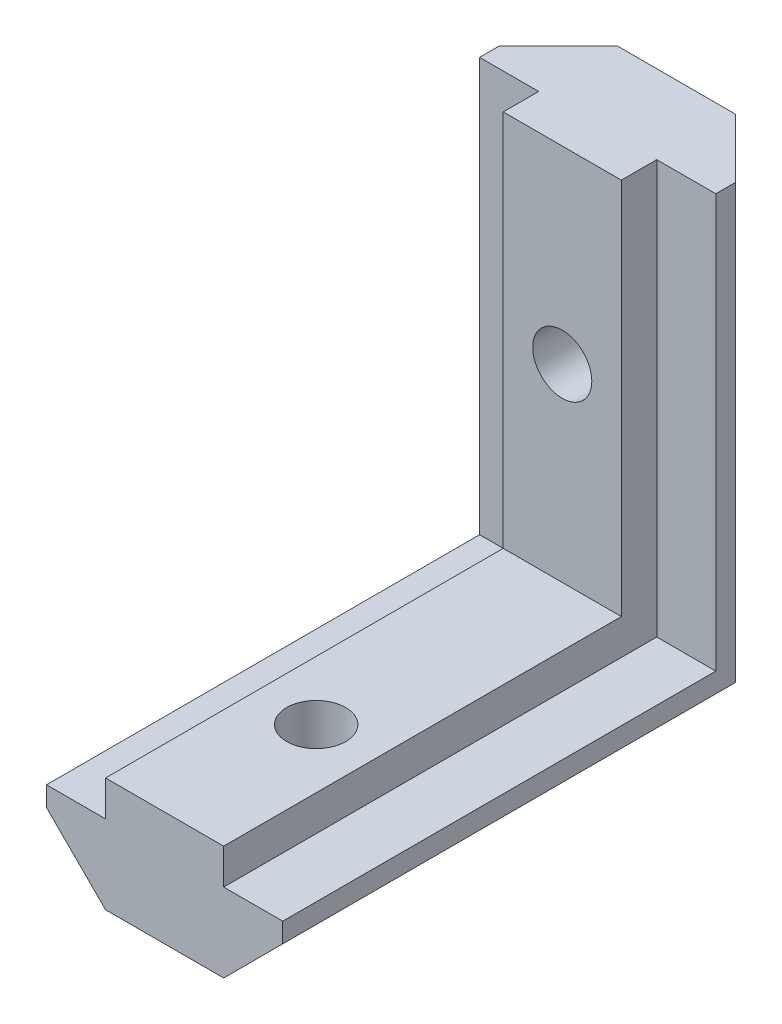
from build123d import *

# Parameters (mm, degrees)
ESTRUSIONE_ESTRUSIONE1_DEPTH = 26
ESTRUSIONE_ESTRUSIONE2_DEPTH = 25
TAGLIO_ESTRUSIONE1_DEPTH     = 5
TAGLIO_ESTRUSIONE2_DEPTH     = 5
SCHIZZO5_R                   = 1.5
TAGLIO_ESTRUSIONE3_DEPTH     = 6.8
SCHIZZO6_R                   = 1.5
TAGLIO_ESTRUSIONE4_DEPTH     = 6.8


with BuildPart() as part:
    # Schizzo1 → Estrusione-Estrusione1 (new body)
    with BuildSketch(Plane.XY):
        Polygon((3, 0), (-3, 0), (-6, 3), (-6, 4), (-3, 4), (-3, 5.8), (3, 5.8), (3, 4), (6, 4), (6, 3), align=None)
    extrude(amount=ESTRUSIONE_ESTRUSIONE1_DEPTH)

    # Schizzo2 → Estrusione-Estrusione2 (add)
    with BuildSketch(Plane(origin=(0, 0, 0), x_dir=(1, 0, 0), z_dir=(0, 1, 0))):
        Polygon((3, 0), (6, -3), (6, -4), (3, -4), (3, -5.8), (-3, -5.8), (-3, -4), (-6, -4), (-6, -3), (-3, 0), align=None)
    extrude(amount=ESTRUSIONE_ESTRUSIONE2_DEPTH)

    # Schizzo3 → Taglio-Estrusione1 (cut)
    with BuildSketch(Plane(origin=(0, 0, 0), x_dir=(1, 0, 0), z_dir=(0, 1, 0))):
        Polygon((-3, 0), (-6, -3), (-6, 0), align=None)
        Polygon((6, -3), (6, 0), (3, 0), align=None)
    extrude(amount=TAGLIO_ESTRUSIONE1_DEPTH, mode=Mode.SUBTRACT)

    # Schizzo4 → Taglio-Estrusione2 (cut)
    with BuildSketch(Plane.XY.offset(4)):
        Polygon((-6, 3), (-3, 0), (-6, 0), align=None)
        Polygon((3, 0), (6, 0), (6, 3), align=None)
    extrude(amount=-TAGLIO_ESTRUSIONE2_DEPTH, mode=Mode.SUBTRACT)

    # Schizzo5 → Taglio-Estrusione3 (cut, through all)
    with BuildSketch(Plane.XY.offset(5.8)):
        with Locations((0, 15.4)):
            Circle(SCHIZZO5_R)
    extrude(amount=-TAGLIO_ESTRUSIONE3_DEPTH, mode=Mode.SUBTRACT)

    # Schizzo6 → Taglio-Estrusione4 (cut, through all)
    with BuildSketch(Plane(origin=(0, 5.8, 0), x_dir=(1, 0, 0), z_dir=(0, 1, 0))):
        with Locations((0, -18.3)):
            Circle(SCHIZZO6_R)
    extrude(amount=-TAGLIO_ESTRUSIONE4_DEPTH, mode=Mode.SUBTRACT)


solid = part.part
